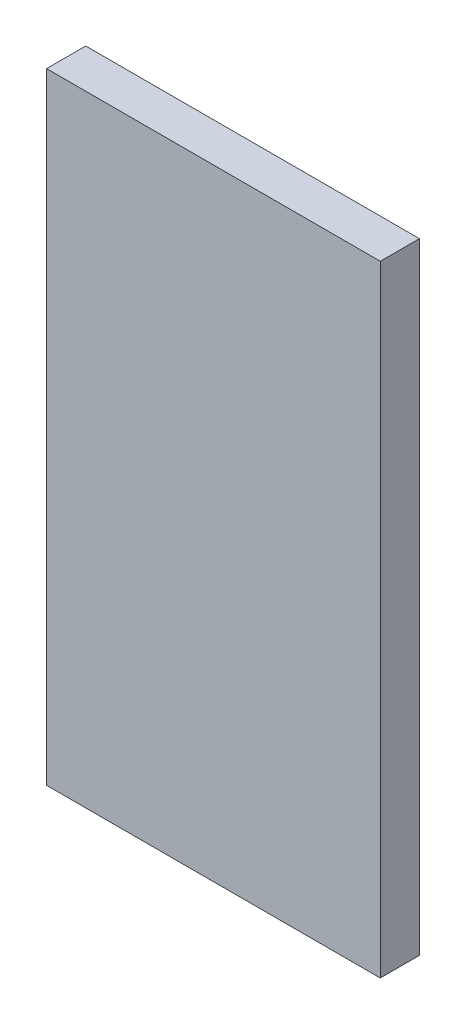
from build123d import *

# Parameters (mm, degrees)
SKETCH2_W           = 42.60153592
SKETCH2_H           = 79.248961499
BOSS_EXTRUDE1_DEPTH = 5


with BuildPart() as part:
    # Sketch2 → Boss-Extrude1 (new body)
    with BuildSketch(Plane.XY):
        with Locations((-21.30076796, -293.322457723)):
            Rectangle(SKETCH2_W, SKETCH2_H)
    extrude(amount=-BOSS_EXTRUDE1_DEPTH)


solid = part.part
